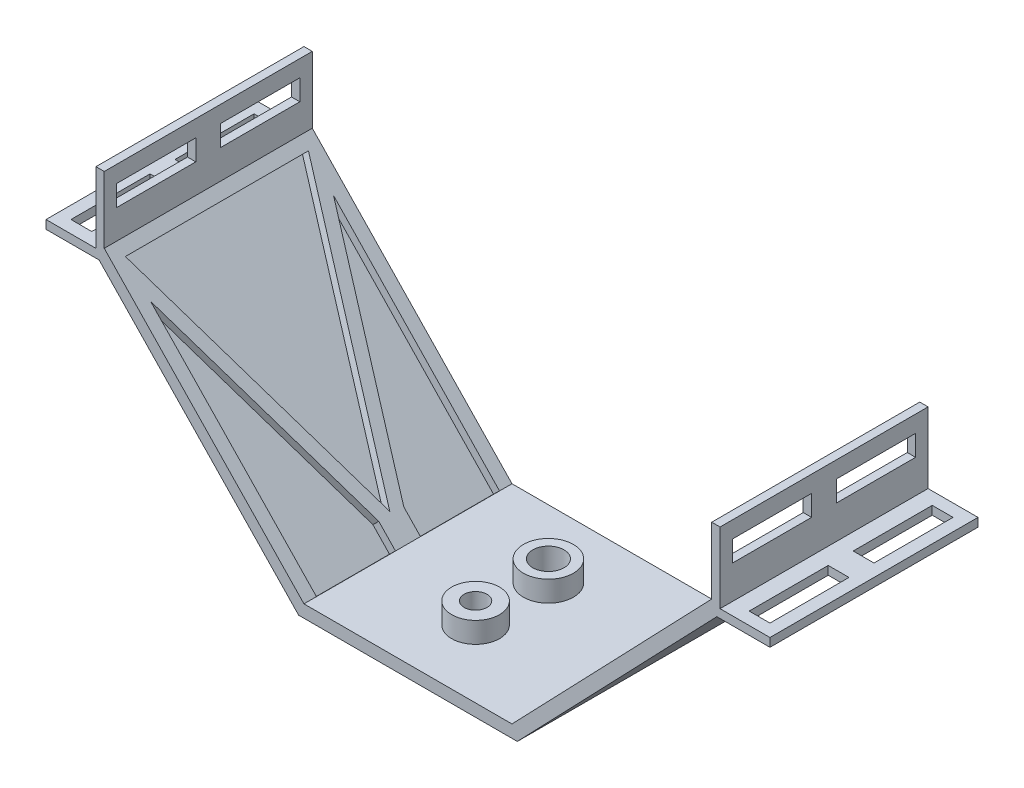
from build123d import *

# Parameters (mm, degrees)
SKETCH1_W               = 50
SKETCH1_H               = 50
SKETCH1_R               = 3.75
SKETCH1_R_2             = 2.75
BOSS_EXTRUDE1_DEPTH     = 3
BOSS_EXTRUDE2_DEPTH     = 50
CUT_EXTRUDE2_DEPTH      = 2
SKETCH10_W              = 50
SKETCH10_H              = 2.047418662
BOSS_EXTRUDE6_DEPTH     = 2
SKETCH11_W              = 5
SKETCH11_H              = 19
CUT_EXTRUDE4_DEPTH      = 4
SKETCH12_W              = 2
SKETCH12_H              = 50
BOSS_EXTRUDE7_DEPTH     = 10
SKETCH13_W              = 19
SKETCH13_H              = 5
CUT_EXTRUDE5_DEPTH      = 10
SKETCH14_R              = 5.75
SKETCH14_R_2            = 3.75
SKETCH14_R_3            = 4.75
SKETCH14_R_4            = 2.75
BOSS_EXTRUDE8_DEPTH     = 5
SKETCH15_W              = 50
SKETCH15_H              = 3
CUT_EXTRUDE6_DEPTH      = 161
CUT_EXTRUDE6_DEPTH_BACK = 15
SKETCH16_R              = 3.75
SKETCH16_R_2            = 2.75
BOSS_EXTRUDE9_DEPTH     = 8
SKETCH17_R              = 3.75
CUT_EXTRUDE7_DEPTH      = 9
SKETCH18_R              = 6
SKETCH18_R_2            = 4.75
BOSS_EXTRUDE10_DEPTH    = 8


with BuildPart() as part:
    # Sketch1 → Boss-Extrude1 (new body)
    with BuildSketch(Plane(origin=(0, 0, 0), x_dir=(1, 0, 0), z_dir=(0, 1, 0))):
        with Locations((0, 8.75)):
            Rectangle(SKETCH1_W, SKETCH1_H)
        Circle(SKETCH1_R, mode=Mode.SUBTRACT)
        with Locations((0, 17.5)):
            Circle(SKETCH1_R_2, mode=Mode.SUBTRACT)
    extrude(amount=BOSS_EXTRUDE1_DEPTH)

    # Sketch2 → Boss-Extrude2 (add)
    with BuildSketch(Plane.XY.offset(16.25)):
        Polygon((-25, 0), (-26.278653628, 0), (-74.233131713, 49.952581338), (-85, 49.952581338), (-85, 52), (-75, 52), (-75, 62), (-73, 62), (-73, 53), (-25, 3), align=None)
    boss_extrude2 = extrude(amount=-BOSS_EXTRUDE2_DEPTH)

    # Sketch3 → Cut-Extrude2 (cut)
    with BuildSketch(Plane(origin=(-11.511240633, -11.050791007, 0), x_dir=(0, 0, -1), z_dir=(0.721387321, 0.692531828, 0))):
        Polygon((-13.25, 85.788351472), (30.75, 85.788351472), (8.75, 25.788351472), align=None)
        Polygon((30.75, 77.073872213), (11.75, 25.255690395), (11.75, 19.477457668), (30.75, 19.477457668), (30.75, 22.897932802), align=None)
        Polygon((-13.25, 77.073872213), (-13.25, 19.477457668), (5.75, 19.477457668), (5.75, 25.255690395), align=None)
    cut_extrude2 = extrude(amount=-CUT_EXTRUDE2_DEPTH, mode=Mode.SUBTRACT)

    # Mirror1: Boss-Extrude2, Cut-Extrude2 across plane
    add(boss_extrude2.mirror(Plane(origin=(0, 0, 0), x_dir=(0, 0, 1), z_dir=(1, 0, 0))))
    add(cut_extrude2.mirror(Plane(origin=(0, 0, 0), x_dir=(0, 0, 1), z_dir=(1, 0, 0))), mode=Mode.SUBTRACT)

    # Sketch10 → Boss-Extrude6 (add)
    with BuildSketch(Plane(origin=(85, 0, 0), x_dir=(0, 0, -1), z_dir=(1, 0, 0))):
        with Locations((8.75, 50.976290669)):
            Rectangle(SKETCH10_W, SKETCH10_H)
    boss_extrude6 = extrude(amount=BOSS_EXTRUDE6_DEPTH)

    # Sketch11 → Cut-Extrude4 (cut)
    with BuildSketch(Plane(origin=(0, 49.952581338, 0), x_dir=(-1, 0, 0), z_dir=(0, -1, 0))):
        with Locations((-81.5, -3.75)):
            Rectangle(SKETCH11_W, SKETCH11_H)
        with Locations((-81.5, 21.25)):
            Rectangle(SKETCH11_W, SKETCH11_H)
    cut_extrude4 = extrude(amount=-CUT_EXTRUDE4_DEPTH, mode=Mode.SUBTRACT)

    # Mirror2: Boss-Extrude6, Cut-Extrude4 across plane
    add(boss_extrude6.mirror(Plane(origin=(0, 0, 0), x_dir=(0, 0, 1), z_dir=(1, 0, 0))))
    add(cut_extrude4.mirror(Plane(origin=(0, 0, 0), x_dir=(0, 0, 1), z_dir=(1, 0, 0))), mode=Mode.SUBTRACT)

    # Sketch12 → Boss-Extrude7 (add)
    with BuildSketch(Plane(origin=(0, 62, 0), x_dir=(1, 0, 0), z_dir=(0, 1, 0))):
        with Locations((74, 8.75)):
            Rectangle(SKETCH12_W, SKETCH12_H)
        with Locations((-74, 8.75)):
            Rectangle(SKETCH12_W, SKETCH12_H)
    extrude(amount=BOSS_EXTRUDE7_DEPTH)

    # Sketch13 → Cut-Extrude5 (cut)
    with BuildSketch(Plane.ZY.offset(-73)):
        with Locations((-21.25, 62.5)):
            Rectangle(SKETCH13_W, SKETCH13_H)
        with Locations((3.75, 62.5)):
            Rectangle(SKETCH13_W, SKETCH13_H)
    cut_extrude5 = extrude(amount=-CUT_EXTRUDE5_DEPTH, mode=Mode.SUBTRACT)

    # Mirror3: Cut-Extrude5 across plane
    add(cut_extrude5.mirror(Plane(origin=(0, 0, 0), x_dir=(0, 0, 1), z_dir=(1, 0, 0))), mode=Mode.SUBTRACT)

    # Sketch14 → Boss-Extrude8 (add)
    with BuildSketch(Plane(origin=(0, 3, 0), x_dir=(1, 0, 0), z_dir=(0, 1, 0))):
        Circle(SKETCH14_R)
        Circle(SKETCH14_R_2, mode=Mode.SUBTRACT)
        with Locations((0, 17.5)):
            Circle(SKETCH14_R_3)
        with Locations((0, 17.5)):
            Circle(SKETCH14_R_4, mode=Mode.SUBTRACT)
    extrude(amount=BOSS_EXTRUDE8_DEPTH)

    # Sketch15 → Cut-Extrude6 (cut, two sides)
    with BuildSketch(Plane.ZY.offset(-73)) as cut_extrude6_sk:
        with Locations((-8.75, 70.5)):
            Rectangle(SKETCH15_W, SKETCH15_H)
    extrude(amount=CUT_EXTRUDE6_DEPTH, mode=Mode.SUBTRACT)
    extrude(cut_extrude6_sk.sketch, amount=-CUT_EXTRUDE6_DEPTH_BACK, mode=Mode.SUBTRACT)

    # Sketch16 → Boss-Extrude9 (add)
    with BuildSketch(Plane(origin=(0, 8, 0), x_dir=(1, 0, 0), z_dir=(0, 1, 0))):
        Circle(SKETCH16_R)
        Circle(SKETCH16_R_2, mode=Mode.SUBTRACT)
    extrude(amount=-BOSS_EXTRUDE9_DEPTH)

    # Sketch17 → Cut-Extrude7 (cut, through all)
    with BuildSketch(Plane(origin=(0, 8, 0), x_dir=(1, 0, 0), z_dir=(0, 1, 0))):
        with Locations((0, 17.5)):
            Circle(SKETCH17_R)
    extrude(amount=-CUT_EXTRUDE7_DEPTH, mode=Mode.SUBTRACT)

    # Sketch18 → Boss-Extrude10 (add)
    with BuildSketch(Plane(origin=(0, 8, 0), x_dir=(1, 0, 0), z_dir=(0, 1, 0))):
        with Locations((0, 17.5)):
            Circle(SKETCH18_R)
        with Locations((0, 17.5)):
            Circle(SKETCH18_R_2, mode=Mode.SUBTRACT)
    extrude(amount=-BOSS_EXTRUDE10_DEPTH)


solid = part.part
